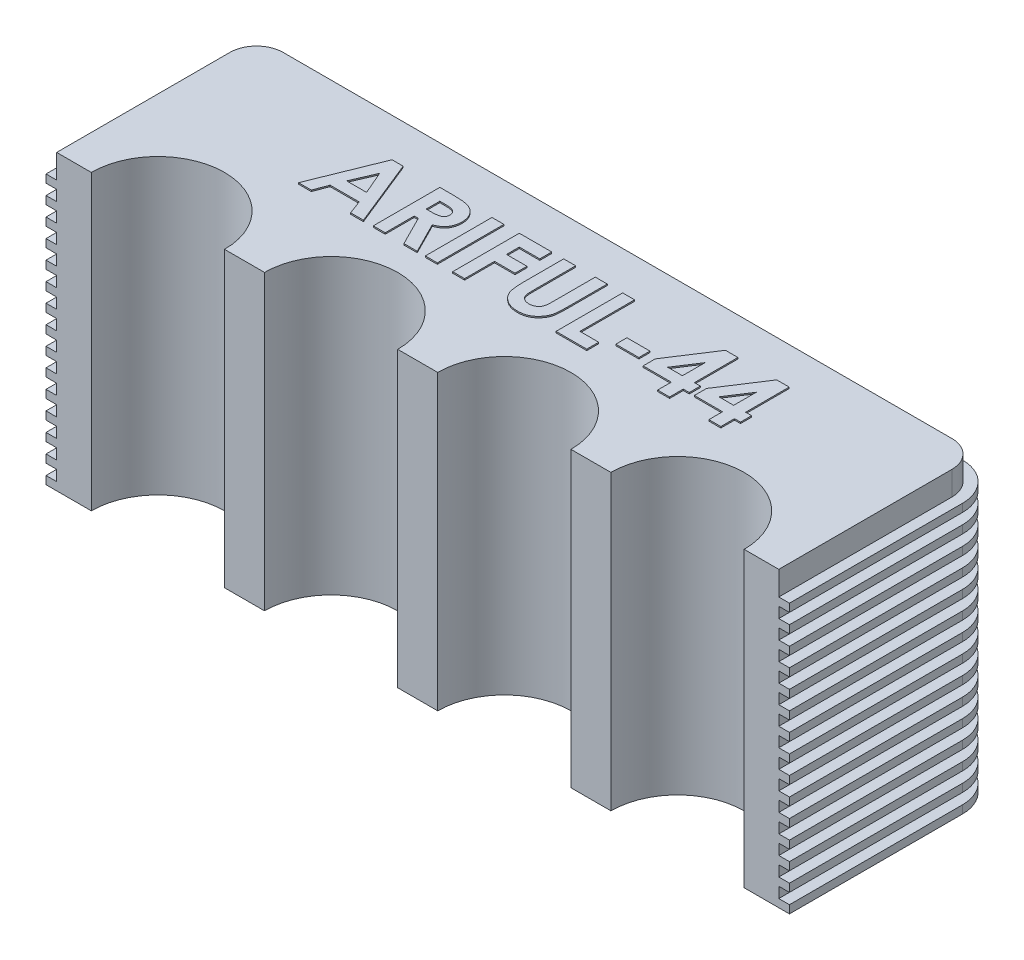
from build123d import *

# Parameters (mm, degrees)
BOSS_EXTRUDE1_DEPTH = 110
BOSS_EXTRUDE2_DEPTH = 3
LPATTERN2_COUNT     = 15
LPATTERN2_PITCH     = 7
SKETCH5_W           = 4.487179488
SKETCH5_H           = 25
SKETCH5_W_2         = 8.653846154
SKETCH5_H_2         = 4.166666667
BOSS_EXTRUDE3_DEPTH = 0.5


with BuildPart() as part:
    # Sketch1 → Boss-Extrude1 (new body)
    with BuildSketch(Plane(origin=(0, 0, 0), x_dir=(1, 0, 0), z_dir=(0, 1, 0))):
        with BuildLine():
            Line((122.5, -37.5), (135.5, -37.5))
            Line((135.5, -37.5), (135.5, 27.5))
            ThreePointArc((135.5, 27.5), (132.571067812, 34.571067812), (125.5, 37.5))
            Line((125.5, 37.5), (-125.5, 37.5))
            ThreePointArc((-125.5, 37.5), (-132.571067812, 34.571067812), (-135.5, 27.5))
            Line((-135.5, 27.5), (-135.5, -37.5))
            Line((-135.5, -37.5), (-122.5, -37.5))
            ThreePointArc((-122.5, -37.5), (-97.5, -12.5), (-72.5, -37.5))
            Line((-72.5, -37.5), (-57.5, -37.5))
            ThreePointArc((-57.5, -37.5), (-32.5, -12.5), (-7.5, -37.5))
            Line((-7.5, -37.5), (7.5, -37.5))
            ThreePointArc((7.5, -37.5), (32.5, -12.5), (57.5, -37.5))
            Line((57.5, -37.5), (72.5, -37.5))
            ThreePointArc((72.5, -37.5), (97.5, -12.5), (122.5, -37.5))
        make_face()
    extrude(amount=BOSS_EXTRUDE1_DEPTH)

    # Sketch4 → Boss-Extrude2 (add)
    with BuildSketch(Plane(origin=(0, 0, 0), x_dir=(1, 0, 0), z_dir=(0, 1, 0))):
        with BuildLine():
            ThreePointArc((135.5, 27.5), (132.571067812, 34.571067812), (125.5, 37.5))
            Line((125.5, 37.5), (-125.5, 37.5))
            ThreePointArc((-125.5, 37.5), (-132.571067812, 34.571067812), (-135.5, 27.5))
            Line((-135.5, 27.5), (-135.5, -37.5))
            Line((-135.5, -37.5), (-139.5, -37.5))
            Line((-139.5, -37.5), (-139.5, 27.5))
            ThreePointArc((-139.5, 27.5), (-135.399494937, 37.399494937), (-125.5, 41.5))
            Line((-125.5, 41.5), (125.5, 41.5))
            ThreePointArc((125.5, 41.5), (135.399494937, 37.399494937), (139.5, 27.5))
            Line((139.5, 27.5), (139.5, -37.5))
            Line((139.5, -37.5), (135.5, -37.5))
            Line((135.5, -37.5), (135.5, 27.5))
        make_face()
    boss_extrude2 = extrude(amount=BOSS_EXTRUDE2_DEPTH)

    # LPattern2: Boss-Extrude2 ×15
    with Locations(*[(0, i * LPATTERN2_PITCH, 0) for i in range(1, LPATTERN2_COUNT)]):
        add(boss_extrude2)

    # Sketch5 → Boss-Extrude3 (add)
    with BuildSketch(Plane(origin=(0, 110, 0), x_dir=(1, 0, 0), z_dir=(0, 1, 0))):
        Polygon((-69.673466599, 22.541366795), (-65.511807945, 22.541366795), (-55.415654099, -2.458633205), (-60.208322368, -2.458633205), (-62.151431342, 2.669571923), (-73.043859227, 2.669571923), (-74.986968201, -2.458633205), (-79.774628458, -2.458633205), align=None)
        Polygon((-67.595141278, 15.835637628), (-71.341134868, 7.15675141), (-63.849147689, 7.15675141), align=None, mode=Mode.SUBTRACT)
        with BuildLine():
            Line((-51.729756663, 22.541366795), (-46.501391278, 22.541366795))
            add(Edge.make_bspline(
                [(-46.501391278, 22.541366795), (-46.155797918, 22.540140137), (-45.491124537, 22.537780928), (-44.532701826, 22.500558859), (-43.652258762, 22.448761294), (-42.848491768, 22.369716836), (-42.121744709, 22.264913439), (-41.471289216, 22.141367576), (-40.8971443, 22.000560578), (-40.394467841, 21.82510395), (-39.940827195, 21.627191533), (-39.517971044, 21.399786536), (-39.116570553, 21.145421188), (-38.739308652, 20.857402445), (-38.382906845, 20.540911696), (-38.046692759, 20.19563036), (-37.73541741, 19.818630594), (-37.45100823, 19.412294559), (-37.191792155, 18.984838368), (-36.962699512, 18.53567512), (-36.776400993, 18.064492454), (-36.611786282, 17.578099976), (-36.493219638, 17.069544611), (-36.410758272, 16.543777232), (-36.350383285, 15.998947081), (-36.346912012, 15.628813667), (-36.345141278, 15.440004616)],
                knots=[0, 0, 0, 0, 0.001036707, 0.00199388, 0.00287701, 0.003682288, 0.004416026, 0.005078997, 0.005668094, 0.006187577, 0.006674205, 0.00715144, 0.007626568, 0.008098333, 0.008573698, 0.009055354, 0.009542677, 0.010038698, 0.010541997, 0.011041445, 0.011549209, 0.012060737, 0.012580631, 0.01311332, 0.013656983, 0.014223088, 0.014223088, 0.014223088, 0.014223088], degree=3))
            add(Edge.make_bspline(
                [(-36.345141278, 15.440004616), (-36.349741008, 15.24293134), (-36.35876024, 14.856506565), (-36.40734273, 14.288880087), (-36.496136259, 13.745814776), (-36.630626978, 13.228900662), (-36.78520659, 12.731704145), (-36.990757822, 12.263398811), (-37.222742703, 11.817173839), (-37.498264369, 11.39934125), (-37.800635936, 11.000620146), (-38.152287709, 10.636287014), (-38.530438054, 10.286760325), (-38.956344178, 9.973933247), (-39.411231744, 9.676653543), (-39.90413889, 9.407238962), (-40.431848735, 9.158917042), (-40.802854889, 9.020435587), (-40.992577176, 8.94962)],
                knots=[0, 0, 0, 0, 0.000591285, 0.001159402, 0.001707728, 0.002239734, 0.002760784, 0.003267781, 0.003771827, 0.004267722, 0.004767571, 0.005270621, 0.005784693, 0.006310534, 0.006853667, 0.007414027, 0.007994309, 0.008601601, 0.008601601, 0.008601601, 0.008601601], degree=3))
            Line((-40.992577176, 8.94962), (-35.223346407, -2.458633205))
            Line((-35.223346407, -2.458633205), (-40.211327176, -2.458633205))
            Line((-40.211327176, -2.458633205), (-45.720141278, 8.438802693))
            Line((-45.720141278, 8.438802693), (-47.242577176, 8.438802693))
            Line((-47.242577176, 8.438802693), (-47.242577176, -2.458633205))
            Line((-47.242577176, -2.458633205), (-51.729756663, -2.458633205))
            Line((-51.729756663, -2.458633205), (-51.729756663, 22.541366795))
        make_face()
        with BuildLine():
            Line((-47.242577176, 12.92598218), (-45.494780701, 12.92598218))
            add(Edge.make_bspline(
                [(-45.494780701, 12.92598218), (-45.281098054, 12.928388817), (-44.871941698, 12.932997011), (-44.28352112, 12.954371724), (-43.749094904, 13.005874222), (-43.266368044, 13.070945702), (-42.832911503, 13.146080123), (-42.452591558, 13.25375231), (-42.119548062, 13.369125784), (-41.837727591, 13.512505084), (-41.596946656, 13.675558446), (-41.38904773, 13.860791119), (-41.217085509, 14.075174352), (-41.07555183, 14.312882132), (-40.965454015, 14.576016928), (-40.885091045, 14.861690115), (-40.840180028, 15.173155879), (-40.835012863, 15.388109666), (-40.832320765, 15.500100769)],
                knots=[0, 0, 0, 0, 0.000641104, 0.001227576, 0.001765769, 0.002250926, 0.002689005, 0.003083877, 0.003435581, 0.003744661, 0.004029414, 0.00430599, 0.004576608, 0.004850588, 0.005133353, 0.005429842, 0.005738638, 0.006074511, 0.006074511, 0.006074511, 0.006074511], degree=3))
            add(Edge.make_bspline(
                [(-40.832320765, 15.500100769), (-40.837410422, 15.63259442), (-40.84740811, 15.892853645), (-40.946616235, 16.267535671), (-41.10453414, 16.614329521), (-41.320996335, 16.931668294), (-41.593602327, 17.20986937), (-41.906439212, 17.455105834), (-42.266258763, 17.649020479), (-42.59942459, 17.776924515), (-42.902527619, 17.853450819), (-43.176068539, 17.910477544), (-43.492830572, 17.950894021), (-43.853052855, 17.993762889), (-44.25581717, 18.02156118), (-44.703318822, 18.041848391), (-45.194272591, 18.050148886), (-45.536513997, 18.052802408), (-45.715133265, 18.054187308)],
                knots=[0, 0, 0, 0, 0.000396772, 0.000779386, 0.001153649, 0.001535639, 0.001925236, 0.00231791, 0.00272359, 0.003146789, 0.003384867, 0.003660854, 0.00398452, 0.004342339, 0.0047491, 0.005195263, 0.00568615, 0.006222031, 0.006222031, 0.006222031, 0.006222031], degree=3))
            Line((-45.715133265, 18.054187308), (-47.242577176, 18.054187308))
            Line((-47.242577176, 18.054187308), (-47.242577176, 12.92598218))
        make_face(mode=Mode.SUBTRACT)
        with Locations((-29.934884868, 10.041366795)):
            Rectangle(SKETCH5_W, SKETCH5_H)
        Polygon((-21.922064355, 22.541366795), (-9.742577176, 22.541366795), (-9.742577176, 18.054187308), (-17.434884868, 18.054187308), (-17.434884868, 13.246495), (-9.742577176, 13.246495), (-9.742577176, 8.759315513), (-17.434884868, 8.759315513), (-17.434884868, -2.458633205), (-21.922064355, -2.458633205), align=None)
        with BuildLine():
            Line((-5.255397689, 22.541366795), (-0.768218201, 22.541366795))
            Line((-0.768218201, 22.541366795), (-0.768218201, 6.275341154))
            add(Edge.make_bspline(
                [(-0.768218201, 6.275341154), (-0.767974211, 6.106702055), (-0.767502945, 5.780977378), (-0.743911149, 5.313669111), (-0.722323028, 4.884114968), (-0.683371931, 4.492785222), (-0.62582781, 4.139512474), (-0.570106325, 3.822027427), (-0.494692804, 3.54601429), (-0.381358338, 3.231839079), (-0.206747132, 2.878846068), (0.078557891, 2.510948655), (0.407775481, 2.175188867), (0.802361725, 1.895715141), (1.245841766, 1.669646086), (1.73577888, 1.502153935), (2.27148243, 1.409050538), (2.641892049, 1.394836599), (2.832543017, 1.387520641)],
                knots=[0, 0, 0, 0, 0.000505834, 0.000977013, 0.00140343, 0.001796104, 0.002155915, 0.002477093, 0.002762593, 0.003012894, 0.003478747, 0.00393648, 0.004403919, 0.004884792, 0.005379775, 0.005892895, 0.006432205, 0.007004194, 0.007004194, 0.007004194, 0.007004194], degree=3))
            add(Edge.make_bspline(
                [(2.832543017, 1.387520641), (3.035086142, 1.393430996), (3.430010946, 1.404955188), (3.998047405, 1.518077602), (4.524336406, 1.698207227), (4.997734615, 1.955298108), (5.417770926, 2.263466586), (5.773322861, 2.614875222), (6.053923142, 3.010224901), (6.236807966, 3.374965085), (6.339488789, 3.710676662), (6.41645318, 4.010622217), (6.472876593, 4.364528282), (6.524065768, 4.76686785), (6.554826519, 5.221808385), (6.588181538, 5.725691195), (6.600406462, 6.281963982), (6.602490112, 6.669307164), (6.60357667, 6.87129468)],
                knots=[0, 0, 0, 0, 0.000606983, 0.001183514, 0.001729938, 0.002269922, 0.002792774, 0.003288541, 0.003762428, 0.004241734, 0.004504643, 0.004814371, 0.005170046, 0.005578775, 0.006030857, 0.006537558, 0.00709365, 0.007699641, 0.007699641, 0.007699641, 0.007699641], degree=3))
            Line((6.60357667, 6.87129468), (6.60357667, 22.541366795))
            Line((6.60357667, 22.541366795), (11.090756158, 22.541366795))
            Line((11.090756158, 22.541366795), (11.090756158, 7.627504616))
            add(Edge.make_bspline(
                [(11.090756158, 7.627504616), (11.090133031, 7.325350481), (11.08893482, 6.744337547), (11.070533906, 5.909381074), (11.031361688, 5.14678227), (10.998461544, 4.456318304), (10.934788498, 3.838919345), (10.868456121, 3.291948924), (10.783909799, 2.81734538), (10.658109957, 2.277066922), (10.441016672, 1.654956064), (10.091033834, 0.93862238), (9.646753274, 0.237288313), (9.121635856, -0.44133098), (8.528730257, -1.071746432), (7.881182463, -1.6251696), (7.189280399, -2.093305922), (6.445794184, -2.464708901), (5.651356563, -2.754375226), (4.79810717, -2.949016407), (3.886627852, -3.080518432), (3.257051859, -3.09315082), (2.932703273, -3.099658846)],
                knots=[0, 0, 0, 0, 0.000906464, 0.001743042, 0.002505067, 0.003197333, 0.003816243, 0.004366601, 0.004849919, 0.005261705, 0.006029827, 0.006820475, 0.007648601, 0.008516086, 0.009391114, 0.010240131, 0.011066574, 0.011890769, 0.012727242, 0.01359698, 0.014512036, 0.015484416, 0.015484416, 0.015484416, 0.015484416], degree=3))
            add(Edge.make_bspline(
                [(2.932703273, -3.099658846), (2.71719962, -3.096028972), (2.292015334, -3.088867304), (1.666707251, -3.025720101), (1.062224155, -2.932664869), (0.479701864, -2.796906868), (-0.082881446, -2.621532887), (-0.625376312, -2.405659729), (-1.14576669, -2.150491509), (-1.64114055, -1.858375221), (-2.110888291, -1.542501742), (-2.540213479, -1.192342693), (-2.9438902, -0.83379366), (-3.310256404, -0.451765375), (-3.642063825, -0.050268486), (-3.938629107, 0.371606933), (-4.199511652, 0.813823408), (-4.431273817, 1.284351864), (-4.62963961, 1.807107566), (-4.796869426, 2.400685148), (-4.942965328, 3.074388346), (-5.051535182, 3.829734978), (-5.14996525, 4.664235506), (-5.212266055, 5.580063931), (-5.244858411, 6.577246528), (-5.251795827, 7.26857255), (-5.255397689, 7.627504616)],
                knots=[0, 0, 0, 0, 0.000646344, 0.001275224, 0.001883672, 0.00248013, 0.003067777, 0.003649936, 0.004230023, 0.004804636, 0.005374142, 0.00592632, 0.006465327, 0.006993073, 0.007512459, 0.008026531, 0.008538428, 0.009051327, 0.009598211, 0.010213198, 0.010899807, 0.011664739, 0.012501497, 0.013420273, 0.014417484, 0.015494311, 0.015494311, 0.015494311, 0.015494311], degree=3))
            Line((-5.255397689, 7.627504616), (-5.255397689, 22.541366795))
        make_face()
        Polygon((16.859986927, 22.541366795), (21.347166414, 22.541366795), (21.347166414, 2.028546282), (28.398448465, 2.028546282), (28.398448465, -2.458633205), (16.859986927, -2.458633205), align=None)
        with Locations((36.571525388, 6.67598218)):
            Rectangle(SKETCH5_W_2, SKETCH5_H_2)
        Polygon((54.810708081, 23.182392436), (59.488192055, 23.182392436), (59.488192055, 6.83623859), (61.731781799, 6.83623859), (61.731781799, 2.669571923), (59.488192055, 2.669571923), (59.488192055, -2.458633205), (55.001012568, -2.458633205), (55.001012568, 2.669571923), (44.424089491, 2.669571923), (44.424089491, 7.211839551), align=None)
        Polygon((55.001012568, 6.83623859), (55.001012568, 15.344852372), (49.467158401, 6.83623859), align=None, mode=Mode.SUBTRACT)
        Polygon((74.041477311, 23.182392436), (78.718961286, 23.182392436), (78.718961286, 6.83623859), (80.962551029, 6.83623859), (80.962551029, 2.669571923), (78.718961286, 2.669571923), (78.718961286, -2.458633205), (74.231781799, -2.458633205), (74.231781799, 2.669571923), (63.654858722, 2.669571923), (63.654858722, 7.211839551), align=None)
        Polygon((74.231781799, 6.83623859), (74.231781799, 15.344852372), (68.697927632, 6.83623859), align=None, mode=Mode.SUBTRACT)
    extrude(amount=BOSS_EXTRUDE3_DEPTH)


solid = part.part
